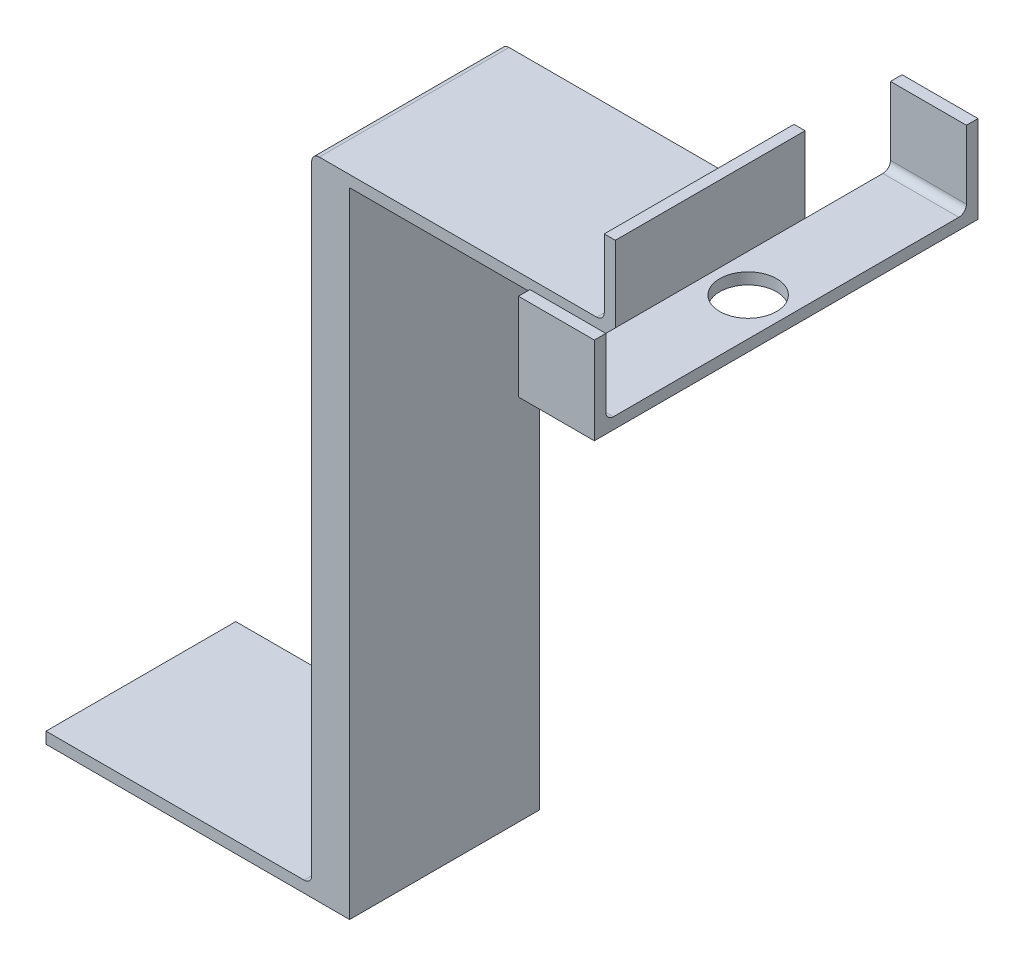
from build123d import *

# Parameters (mm, degrees)
SKETCH1_W           = 101.6
SKETCH1_H           = 63.5
BOSS_EXTRUDE1_DEPTH = 3.81
SKETCH2_W           = 12.7
SKETCH2_H           = 63.5
BOSS_EXTRUDE2_DEPTH = 212.09
SKETCH3_R           = 9.525
BOSS_EXTRUDE3_DEPTH = 3.81
SKETCH4_W           = 25.4
SKETCH4_H           = 3.841083916
SKETCH4_W_2         = 3.700866251
SKETCH4_H_2         = 63.5
SKETCH4_H_3         = 3.885733648
BOSS_EXTRUDE6_DEPTH = 25.4
SKETCH6_W           = 25.4
SKETCH6_H           = 3.885733648
SKETCH6_H_2         = 3.841083916
BOSS_EXTRUDE7_DEPTH = 3.81
FILLET2_R           = 2.54


with BuildPart() as part:
    # Sketch1 → Boss-Extrude1 (new body)
    with BuildSketch(Plane(origin=(0, 0, 0), x_dir=(1, 0, 0), z_dir=(0, 1, 0))):
        with Locations((50.8, -31.75)):
            Rectangle(SKETCH1_W, SKETCH1_H)
    extrude(amount=BOSS_EXTRUDE1_DEPTH)

    # Sketch2 → Boss-Extrude2 (add)
    with BuildSketch(Plane(origin=(0, 3.81, 0), x_dir=(1, 0, 0), z_dir=(0, 1, 0))):
        with Locations((95.25, -31.75)):
            Rectangle(SKETCH2_W, SKETCH2_H)
    extrude(amount=BOSS_EXTRUDE2_DEPTH)

    # Sketch3 → Boss-Extrude3 (add)
    with BuildSketch(Plane(origin=(0, 215.9, 0), x_dir=(1, 0, 0), z_dir=(0, 1, 0))):
        Polygon((101.6, 0), (190.5, 0), (190.5, 28.575), (203.2, 28.575), (215.9, 28.575), (215.9, -92.075), (203.2, -92.075), (190.5, -92.075), (190.5, -63.5), (101.6, -63.5), align=None)
        with Locations((203.2, -31.75)):
            Circle(SKETCH3_R, mode=Mode.SUBTRACT)
    extrude(amount=-BOSS_EXTRUDE3_DEPTH)

    # Sketch4 → Boss-Extrude6 (add)
    with BuildSketch(Plane(origin=(0, 215.9, 0), x_dir=(1, 0, 0), z_dir=(0, 1, 0))):
        with Locations((203.2, -93.995541958)):
            Rectangle(SKETCH4_W, SKETCH4_H)
        with Locations((188.649566875, -31.75)):
            Rectangle(SKETCH4_W_2, SKETCH4_H_2)
        with Locations((203.2, 30.517866824)):
            Rectangle(SKETCH4_W, SKETCH4_H_3)
    extrude(amount=BOSS_EXTRUDE6_DEPTH)

    # Sketch6 → Boss-Extrude7 (add)
    with BuildSketch(Plane.XZ.offset(-215.9)):
        with Locations((203.2, -30.517866824)):
            Rectangle(SKETCH6_W, SKETCH6_H)
        with Locations((203.2, 93.995541958)):
            Rectangle(SKETCH6_W, SKETCH6_H_2)
    extrude(amount=BOSS_EXTRUDE7_DEPTH)

    # Fillet2
    fillet2_edges = [part.edges().sort_by_distance(p)[0] for p in [
        (203.2, 215.9, -28.575),
        (88.9, 215.9, 31.75),
        (88.9, 3.81, 31.75),
        (186.799133749, 215.9, 31.75),
        (203.2, 215.9, 92.075),
    ]]
    fillet(fillet2_edges, radius=FILLET2_R)


solid = part.part
